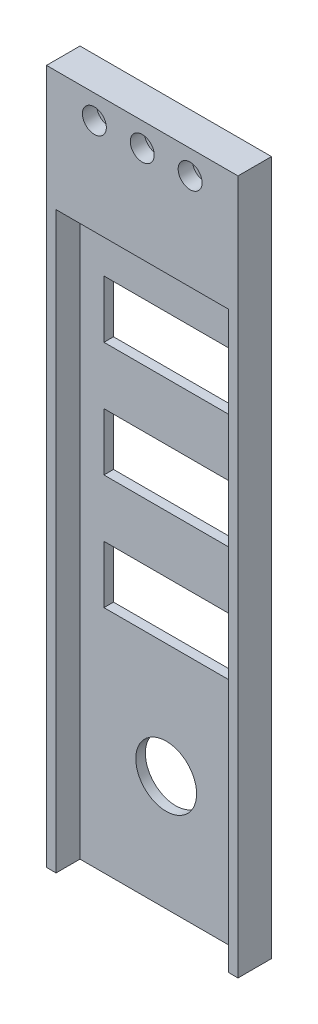
from build123d import *

# Parameters (mm, degrees)
SKETCH1_W           = 40
SKETCH1_H           = 145.1
BOSS_EXTRUDE1_DEPTH = 7
SKETCH2_R           = 1.25
CUT_EXTRUDE1_DEPTH  = 7
SKETCH3_R           = 2.5
CUT_EXTRUDE2_DEPTH  = 3
SKETCH4_R           = 6.35
CUT_EXTRUDE3_DEPTH  = 8
SKETCH5_W           = 36
SKETCH5_H           = 120
CUT_EXTRUDE4_DEPTH  = 5
SKETCH6_W           = 26
SKETCH6_H           = 12
CUT_EXTRUDE5_DEPTH  = 3


with BuildPart() as part:
    # Sketch1 → Boss-Extrude1 (new body)
    with BuildSketch(Plane.XY):
        with Locations((20, 72.55)):
            Rectangle(SKETCH1_W, SKETCH1_H)
    extrude(amount=BOSS_EXTRUDE1_DEPTH)

    # Sketch2 → Cut-Extrude1 (cut)
    with BuildSketch(Plane.XY.offset(7)):
        with Locations((20, 140.1)):
            Circle(SKETCH2_R)
        with Locations((10, 140.1)):
            Circle(SKETCH2_R)
        with Locations((30, 140.1)):
            Circle(SKETCH2_R)
    extrude(amount=-CUT_EXTRUDE1_DEPTH, mode=Mode.SUBTRACT)

    # Sketch3 → Cut-Extrude2 (cut)
    with BuildSketch(Plane.XY.offset(7)):
        with Locations((10, 140.1)):
            Circle(SKETCH3_R)
        with Locations((20, 140.1)):
            Circle(SKETCH3_R)
        with Locations((30, 140.1)):
            Circle(SKETCH3_R)
    extrude(amount=-CUT_EXTRUDE2_DEPTH, mode=Mode.SUBTRACT)

    # Sketch4 → Cut-Extrude3 (cut, through all)
    with BuildSketch(Plane.XY.offset(7)):
        with Locations((20, 24)):
            Circle(SKETCH4_R)
    extrude(amount=-CUT_EXTRUDE3_DEPTH, mode=Mode.SUBTRACT)

    # Sketch5 → Cut-Extrude4 (cut)
    with BuildSketch(Plane.XY.offset(7)):
        with Locations((20, 60)):
            Rectangle(SKETCH5_W, SKETCH5_H)
    extrude(amount=-CUT_EXTRUDE4_DEPTH, mode=Mode.SUBTRACT)

    # Sketch6 → Cut-Extrude5 (cut, through all)
    with BuildSketch(Plane.XY.offset(2)):
        with Locations((20, 102)):
            Rectangle(SKETCH6_W, SKETCH6_H)
        with Locations((20, 78)):
            Rectangle(SKETCH6_W, SKETCH6_H)
        with Locations((20, 54)):
            Rectangle(SKETCH6_W, SKETCH6_H)
    extrude(amount=-CUT_EXTRUDE5_DEPTH, mode=Mode.SUBTRACT)


solid = part.part
